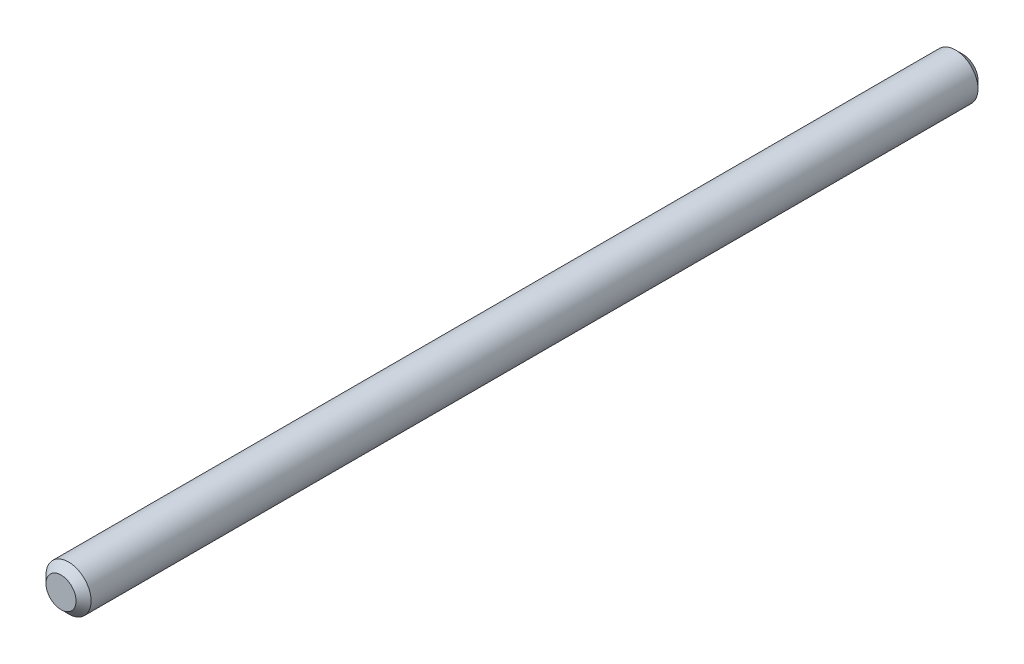
from build123d import *

# Parameters (mm, degrees)
ESQUISSE1_R          = 1.5
BASE_EXTRUSION_DEPTH = 60
CHANFREIN1_SIZE      = 0.5


with BuildPart() as part:
    # Esquisse1 → Base-Extrusion (new body)
    with BuildSketch(Plane.XY):
        Circle(ESQUISSE1_R)
    extrude(amount=BASE_EXTRUSION_DEPTH)

    # Chanfrein1
    chanfrein1_edges = [part.edges().sort_by_distance(p)[0] for p in [
        (-1.5, 0, 0),
        (-1.5, 0, 60),
    ]]
    chamfer(chanfrein1_edges, length=CHANFREIN1_SIZE)


solid = part.part
